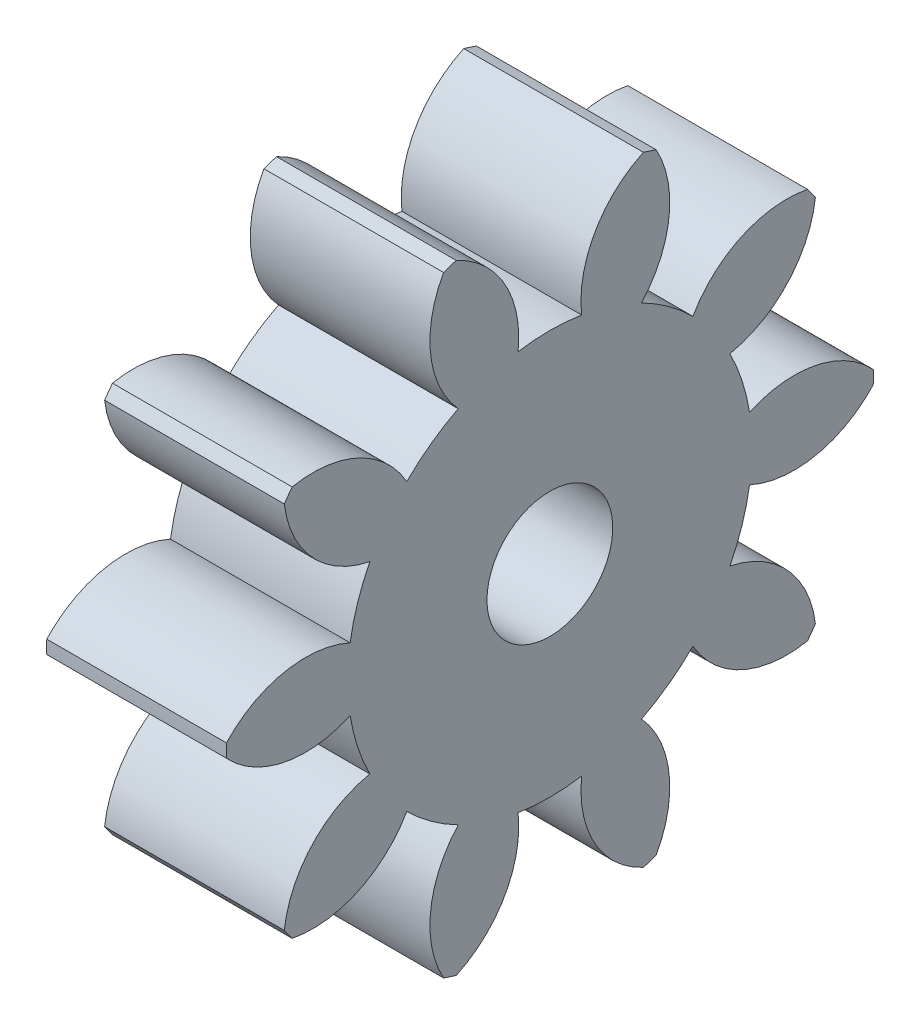
from build123d import *

# Parameters (mm, degrees)
BASPROSKE_W     = 10
BASPROSKE_H     = 18
TOOTHCUT_DEPTH  = 28.349588662
TEETHCUTS_COUNT = 10
TEETHCUTS_ANGLE = 324
BORSKE_R        = 3.5
BORE_DEPTH      = 50.0000508


with BuildPart() as part:
    # BasProSke → Base-Revolve (revolve)
    with BuildSketch(Plane(origin=(0, 0, 0), x_dir=(1, 0, 0), z_dir=(0, 1, 0)), mode=Mode.PRIVATE) as base_revolve_sk:
        with Locations((5, 9)):
            Rectangle(BASPROSKE_W, BASPROSKE_H)
    revolve(base_revolve_sk.sketch.rotate(Axis((-10, 0, 0), (1, 0, 0)), 180), axis=Axis((-10, 0, 0), (1, 0, 0)))

    # TooCutSke → ToothCut (cut, through all)
    with BuildSketch(Plane(origin=(0, 0, 0), x_dir=(0, 0, -1), z_dir=(1, 0, 0))):
        with BuildLine():
            ThreePointArc((1.768949054, 11.109042274), (0, 11.249), (-1.768949054, 11.109042274))
            ThreePointArc((-1.768949054, 11.109042274), (-2.508977513, 14.741789417), (-5.242576524, 17.246171649))
            ThreePointArc((-5.242576524, 17.246171649), (0, 18.0254), (5.242576524, 17.246171649))
            ThreePointArc((5.242576524, 17.246171649), (2.508977513, 14.741789417), (1.768949054, 11.109042274))
        make_face()
    toothcut = extrude(amount=TOOTHCUT_DEPTH, mode=Mode.SUBTRACT)

    # TeethCuts: ToothCut ×10 about axis
    teethcuts_axis = Axis((-10, 0, 0), (1, 0, 0))
    for i in range(1, TEETHCUTS_COUNT):
        add(toothcut.rotate(teethcuts_axis, i * TEETHCUTS_ANGLE / (TEETHCUTS_COUNT - 1)), mode=Mode.SUBTRACT)

    # BorSke → Bore (cut, symmetric)
    with BuildSketch(Plane(origin=(0, 0, 0), x_dir=(0, 0, -1), z_dir=(1, 0, 0))):
        with Locations(Location((0, 0, 0), (0, 0, 180))):
            Circle(BORSKE_R)
    extrude(amount=BORE_DEPTH, both=True, mode=Mode.SUBTRACT)


solid = part.part
